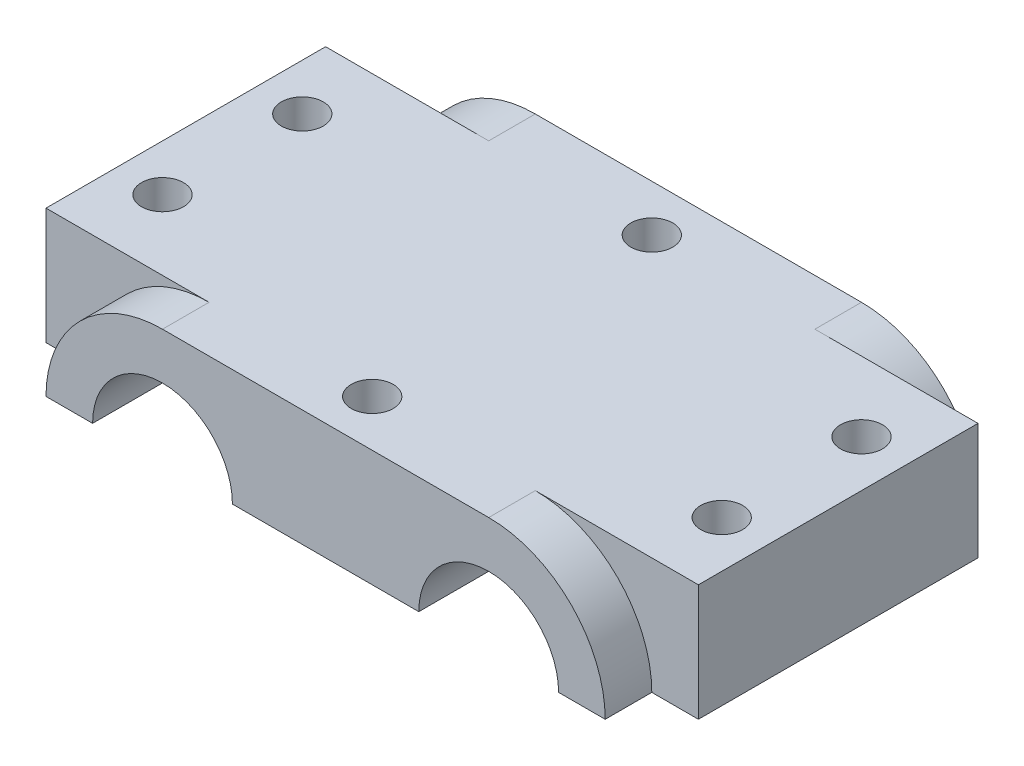
from build123d import *

# Parameters (mm, degrees)
SKETCH1_W                = 70
SKETCH1_H                = 30
BOSS_EXTRUDE1_DEPTH      = 6.25
BOSS_EXTRUDE2_DEPTH      = 5
BOSS_EXTRUDE2_DEPTH_BACK = 35
CUT_EXTRUDE1_DEPTH       = 40
SKETCH5_R                = 2.25
CUT_EXTRUDE2_DEPTH       = 12.5


with BuildPart() as part:
    # Sketch1 → Boss-Extrude1 (new body, symmetric)
    with BuildSketch(Plane(origin=(0, 0, 0), x_dir=(1, 0, 0), z_dir=(0, 1, 0))):
        Rectangle(SKETCH1_W, SKETCH1_H)
    extrude(amount=BOSS_EXTRUDE1_DEPTH, both=True)

    # Sketch2 → Boss-Extrude2 (add, two sides)
    with BuildSketch(Plane.XY.offset(15)) as boss_extrude2_sk:
        with BuildLine():
            Line((5, -6.25), (10, -6.25))
            ThreePointArc((10, -6.25), (17.5, 1.25), (25, -6.25))
            Line((25, -6.25), (30, -6.25))
            ThreePointArc((30, -6.25), (26.338834765, 2.588834765), (17.5, 6.25))
            Line((17.5, 6.25), (-17.5, 6.25))
            ThreePointArc((-17.5, 6.25), (-26.338834765, 2.588834765), (-30, -6.25))
            Line((-30, -6.25), (-25, -6.25))
            ThreePointArc((-25, -6.25), (-17.5, 1.25), (-10, -6.25))
            Line((-10, -6.25), (-5, -6.25))
            Line((-5, -6.25), (5, -6.25))
        make_face()
    extrude(amount=BOSS_EXTRUDE2_DEPTH)
    extrude(boss_extrude2_sk.sketch, amount=-BOSS_EXTRUDE2_DEPTH_BACK)

    # Sketch4 → Cut-Extrude1 (cut)
    with BuildSketch(Plane.XY.offset(20)):
        with BuildLine():
            Line((-25, -6.25), (-10, -6.25))
            ThreePointArc((-10, -6.25), (-17.5, 1.25), (-25, -6.25))
        make_face()
        with BuildLine():
            Line((10, -6.25), (25, -6.25))
            ThreePointArc((25, -6.25), (17.5, 1.25), (10, -6.25))
        make_face()
    extrude(amount=-CUT_EXTRUDE1_DEPTH, mode=Mode.SUBTRACT)

    # Sketch5 → Cut-Extrude2 (cut)
    with BuildSketch(Plane(origin=(0, 6.25, 0), x_dir=(1, 0, 0), z_dir=(0, 1, 0))):
        with Locations((-30, 7.5)):
            Circle(SKETCH5_R)
        with Locations((-30, -7.5)):
            Circle(SKETCH5_R)
        with Locations((30, -7.5)):
            Circle(SKETCH5_R)
        with Locations((30, 7.5)):
            Circle(SKETCH5_R)
        with Locations((0, 15)):
            Circle(SKETCH5_R)
        with Locations((0, -15)):
            Circle(SKETCH5_R)
    extrude(amount=-CUT_EXTRUDE2_DEPTH, mode=Mode.SUBTRACT)


solid = part.part
